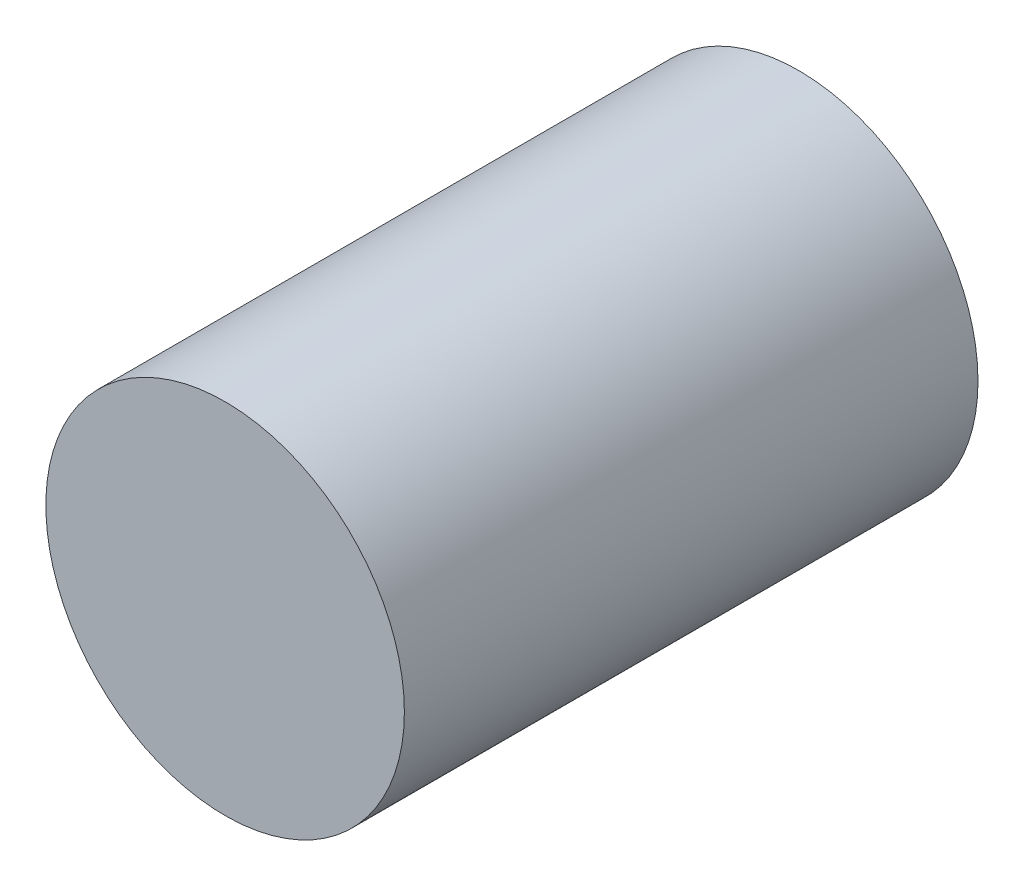
from build123d import *

# Parameters (mm, degrees)
SKETCH_1_R      = 25
EXTRUDE_1_DEPTH = 80


with BuildPart() as part:
    # 草图1 → 凸台-拉伸1 (new body)
    with BuildSketch(Plane.XY):
        Circle(SKETCH_1_R)
    extrude(amount=EXTRUDE_1_DEPTH)


solid = part.part
